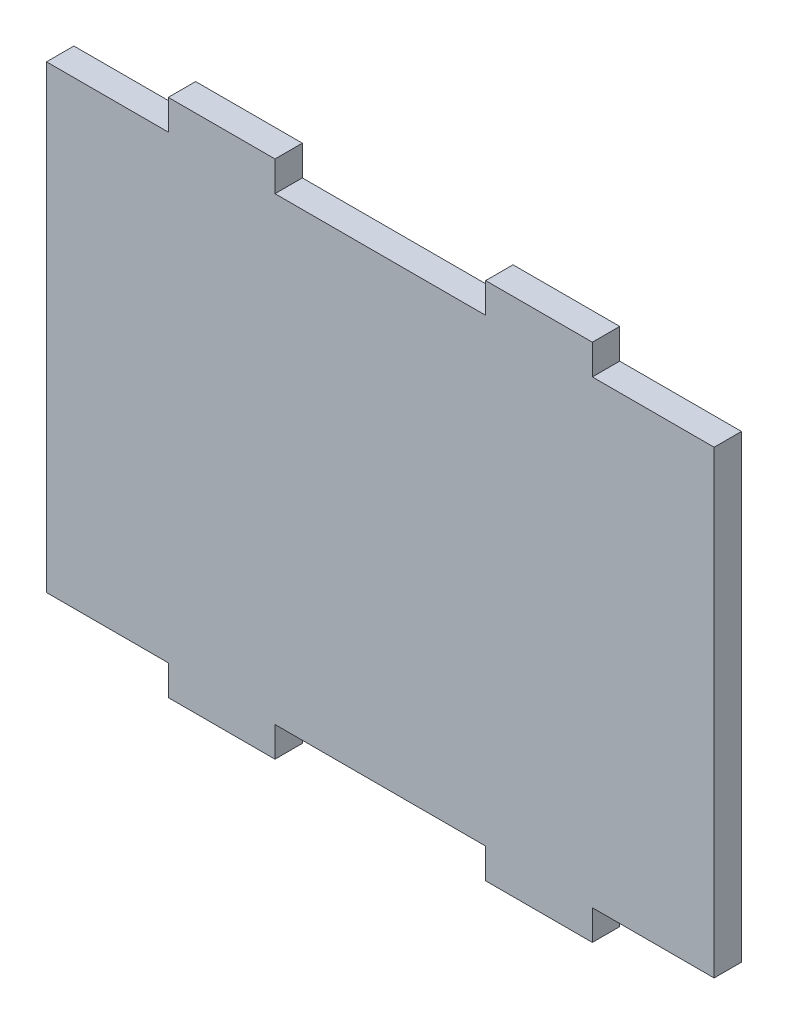
from build123d import *

# Parameters (mm, degrees)
BOSS_EXTRUDE1_DEPTH = 5


with BuildPart() as part:
    # Sketch1 → Boss-Extrude1 (new body)
    with BuildSketch(Plane.XY):
        Polygon((-61, -42), (-61, 42), (-38.75, 42), (-38.75, 47.5), (-19.25, 47.5), (-19.25, 42), (19.25, 42), (19.25, 47.5), (38.75, 47.5), (38.75, 42), (61, 42), (61, -42), (38.75, -42), (38.75, -47.5), (19.25, -47.5), (19.25, -42), (-19.25, -42), (-19.25, -47.5), (-38.75, -47.5), (-38.75, -42), align=None)
    extrude(amount=BOSS_EXTRUDE1_DEPTH)


solid = part.part
